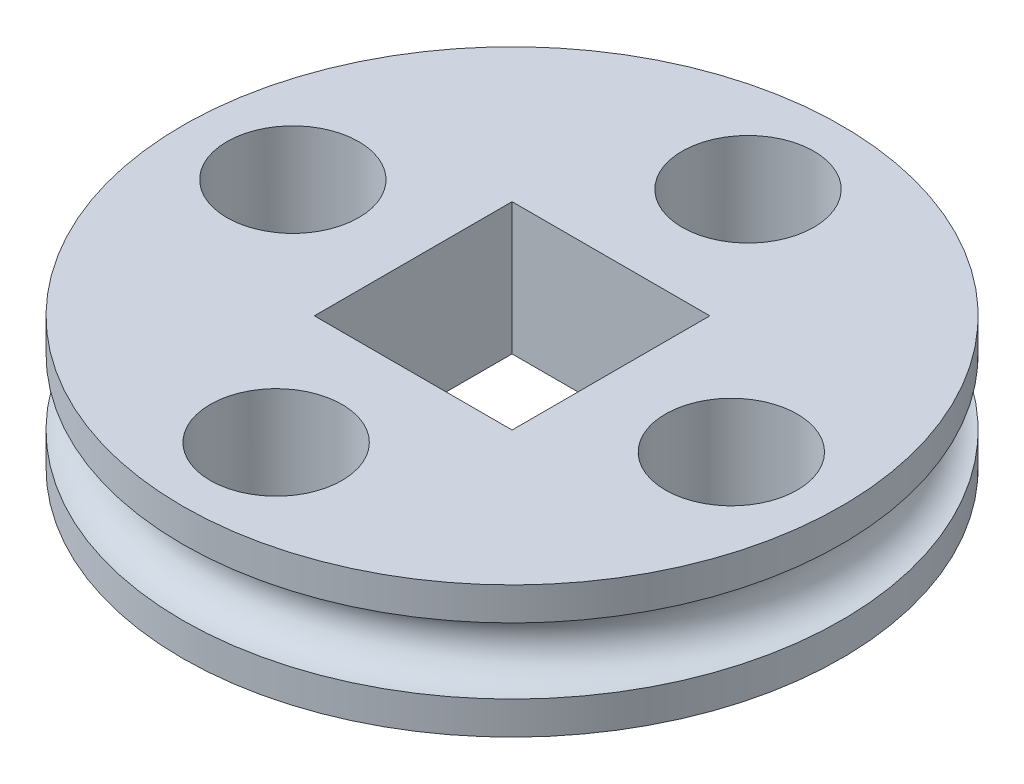
from build123d import *

# Parameters (mm, degrees)
SKIZZE1_R                       = 5
AUFSATZ_LINEAR_AUSTRAGEN1_DEPTH = 2
SKIZZE3_W                       = 3
SKIZZE3_H                       = 3
SCHNITT_LINEAR_AUSTRAGEN1_DEPTH = 3
SKIZZE4_R                       = 1
SCHNITT_LINEAR_AUSTRAGEN2_DEPTH = 3
KREISMUSTER1_COUNT              = 4


with BuildPart() as part:
    # Skizze1 → Aufsatz-Linear austragen1 (new body)
    with BuildSketch(Plane(origin=(0, 0, 0), x_dir=(1, 0, 0), z_dir=(0, 1, 0))):
        Circle(SKIZZE1_R)
    extrude(amount=AUFSATZ_LINEAR_AUSTRAGEN1_DEPTH)

    # Skizze3 → Schnitt-Linear austragen1 (cut)
    with BuildSketch(Plane(origin=(0, 2, 0), x_dir=(1, 0, 0), z_dir=(0, 1, 0))):
        Rectangle(SKIZZE3_W, SKIZZE3_H)
    extrude(amount=-SCHNITT_LINEAR_AUSTRAGEN1_DEPTH, mode=Mode.SUBTRACT)

    # Skizze4 → Schnitt-Linear austragen2 (cut)
    with BuildSketch(Plane(origin=(0, 2, 0), x_dir=(1, 0, 0), z_dir=(0, 1, 0))):
        with Locations((3.452809927, -0.126446108)):
            Circle(SKIZZE4_R)
    schnitt_linear_austragen2 = extrude(amount=-SCHNITT_LINEAR_AUSTRAGEN2_DEPTH, mode=Mode.SUBTRACT)

    # Kreismuster1: Schnitt-Linear austragen2 ×4 about axis
    kreismuster1_axis = Axis((0, 0, 0), (0, 1, 0))
    for i in range(1, KREISMUSTER1_COUNT):
        add(schnitt_linear_austragen2.rotate(kreismuster1_axis, i * 360 / KREISMUSTER1_COUNT), mode=Mode.SUBTRACT)

    # Skizze6 → Schnitt-Rotation2 (revolve, cut)
    with BuildSketch(Plane.XY):
        with BuildLine():
            Line((-5, 1.5), (-5, 0.5))
            ThreePointArc((-5, 0.5), (-4.5, 1), (-5, 1.5))
        make_face()
    revolve(axis=Axis((0, 2, 0), (0, -1, 0)), mode=Mode.SUBTRACT)


solid = part.part
